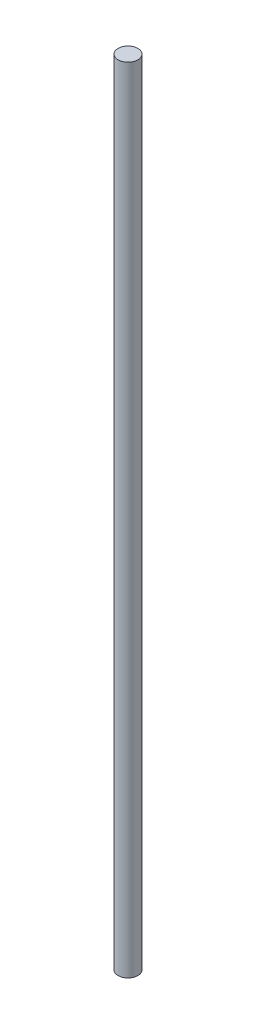
from build123d import *

# Parameters (mm, degrees)
SKETCH1_R           = 1.5875
BOSS_EXTRUDE1_DEPTH = 127


with BuildPart() as part:
    # Sketch1 → Boss-Extrude1 (new body)
    with BuildSketch(Plane(origin=(0, 0, 0), x_dir=(1, 0, 0), z_dir=(0, 1, 0))):
        Circle(SKETCH1_R)
    extrude(amount=BOSS_EXTRUDE1_DEPTH)


solid = part.part
